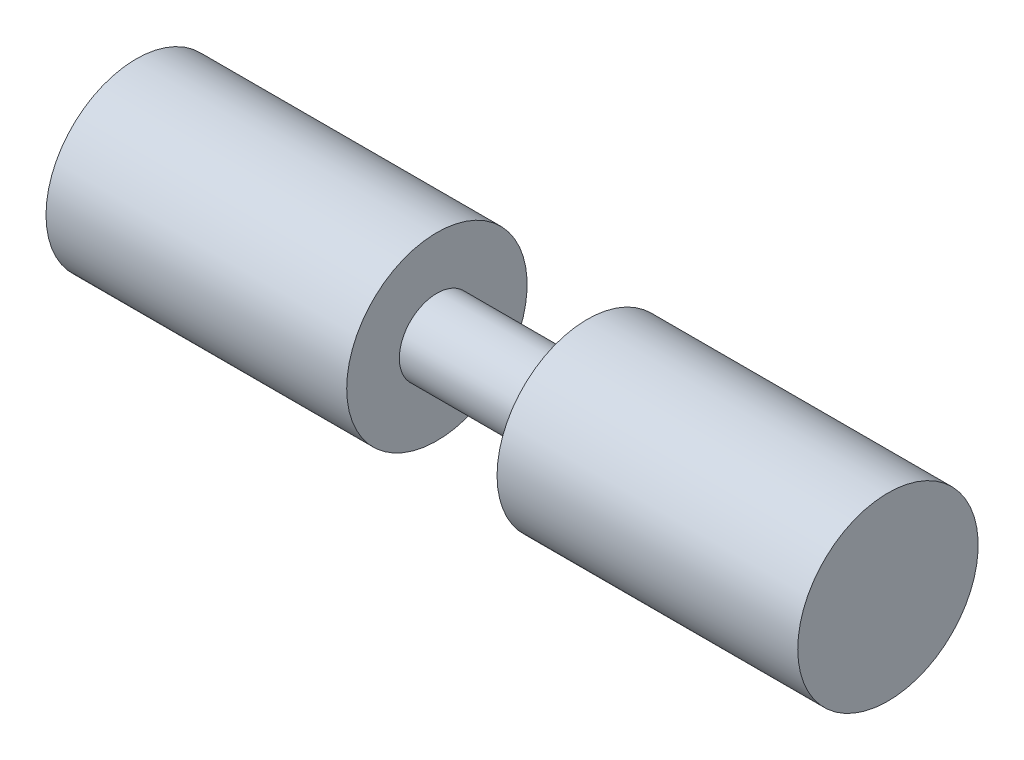
from build123d import *


with BuildPart() as part:
    # Sketch1 → Revolve1 (revolve)
    with BuildSketch(Plane.XY):
        Polygon((0, 0), (0, 15.24), (50.8, 15.24), (50.8, 6.35), (76.2, 6.35), (76.2, 15.24), (127, 15.24), (127, 0), align=None)
    revolve(axis=Axis((0, 0, 0), (1, 0, 0)))


solid = part.part
